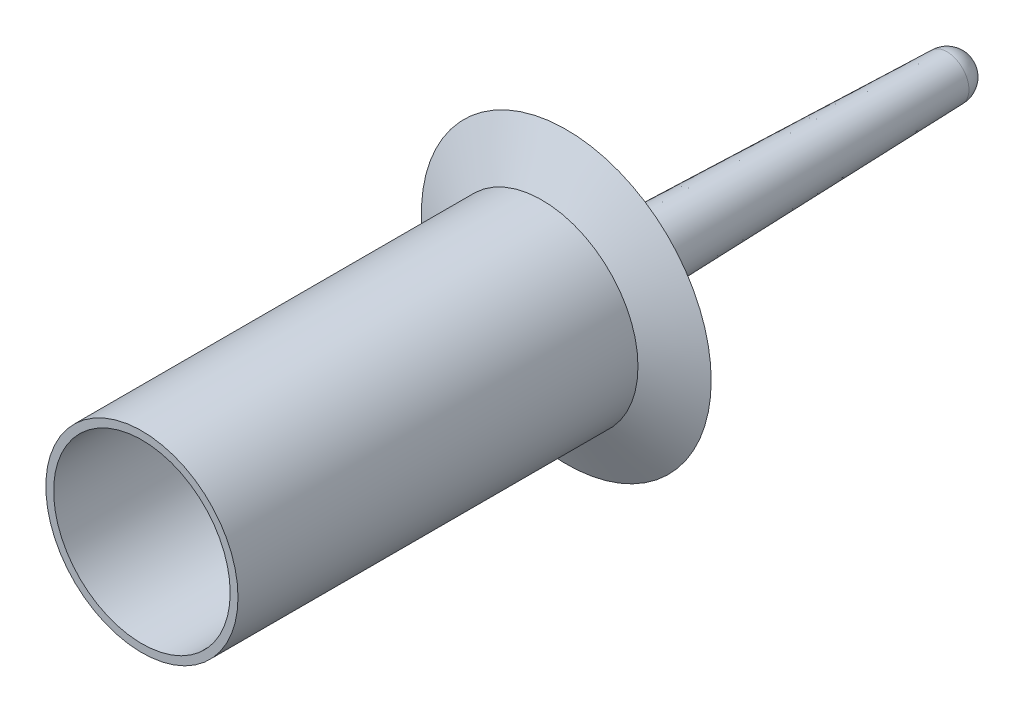
from build123d import *

# Parameters (mm, degrees)
SKETCH1_W = 2.032
SKETCH1_H = 104.0892


with BuildPart() as part:
    # Sketch1 → Revolve1 (revolve)
    with BuildSketch(Plane(origin=(0, 0, 0), x_dir=(1, 0, 0), z_dir=(0, 1, 0))):
        with BuildLine():
            Line((8.4963, 64.4906), (5.715, 157.4546))
            ThreePointArc((5.715, 157.4546), (4.041115254, 161.495715254), (0, 163.1696))
            Line((0, 163.1696), (0, 52.0446))
            Line((0, 52.0446), (22.9743, 52.0446))
            Line((22.9743, 52.0446), (25.0063, 52.0446))
            Line((25.0063, 52.0446), (37.7063, 58.3946))
            Line((37.7063, 58.3946), (14.861271728, 58.330519522))
            ThreePointArc((14.861271728, 58.330519522), (10.4273746, 60.117525142), (8.4963, 64.4906))
        make_face()
        with Locations((23.9903, 0)):
            Rectangle(SKETCH1_W, SKETCH1_H)
    revolve(axis=Axis((0, 0, 52.0446), (0, 0, -1)))


solid = part.part
